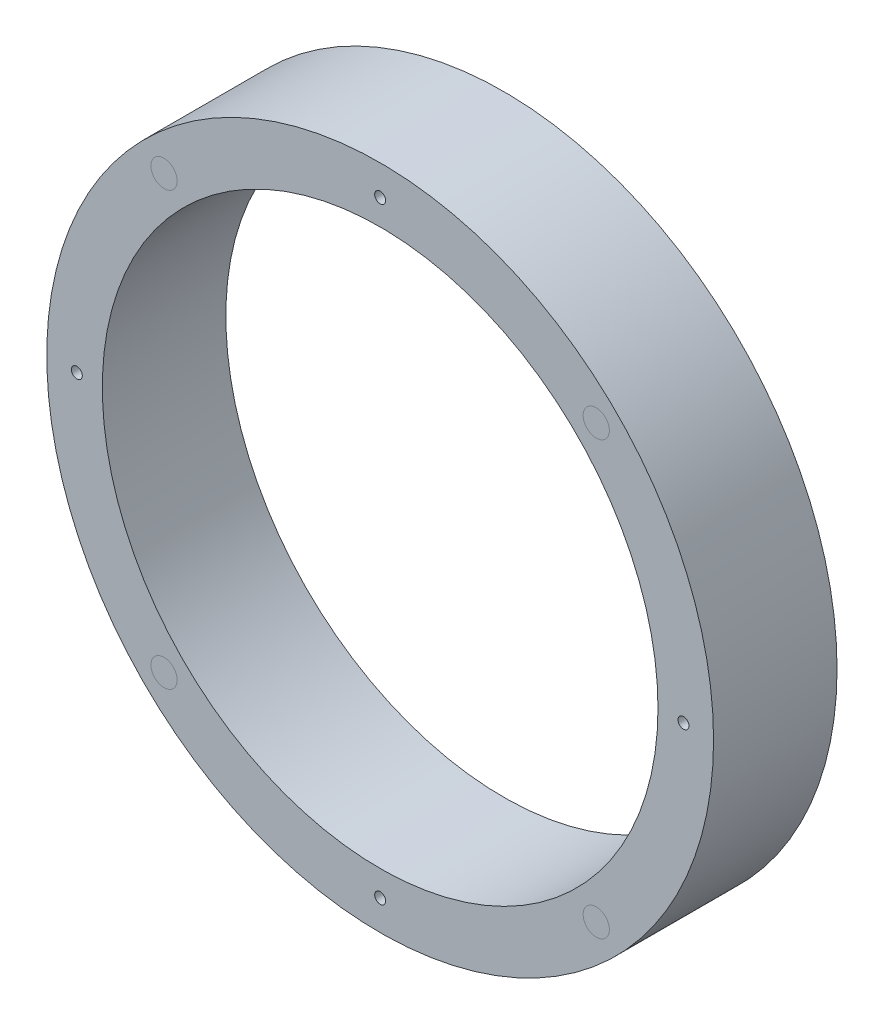
from build123d import *

# Parameters (mm, degrees)
SKETCH1_R             = 76.2
SKETCH1_R_2           = 63.5
SKETCH1_R_3           = 1.25
BOSS_EXTRUDE1_DEPTH   = 28.225
SKETCH2_R             = 2.5
CUT_EXTRUDE1_DEPTH    = 6.725
SKETCH3_R             = 3
CUT_EXTRUDE2_DEPTH    = 29.225
SKETCH4_R             = 3
BOSS_EXTRUDE2_DEPTH   = 6.45
BOSS_EXTRUDE2_2_DEPTH = 6.45
BOSS_EXTRUDE2_3_DEPTH = 6.45
BOSS_EXTRUDE2_4_DEPTH = 6.45


with BuildPart() as part:
    # Sketch1 → Boss-Extrude1 (new body)
    with BuildSketch(Plane.XY):
        Circle(SKETCH1_R)
        Circle(SKETCH1_R_2, mode=Mode.SUBTRACT)
        with Locations((0, 69.3225)):
            Circle(SKETCH1_R_3, mode=Mode.SUBTRACT)
        with Locations((69.3225, 0)):
            Circle(SKETCH1_R_3, mode=Mode.SUBTRACT)
        with Locations((0, -69.3225)):
            Circle(SKETCH1_R_3, mode=Mode.SUBTRACT)
        with Locations((-69.3225, 0)):
            Circle(SKETCH1_R_3, mode=Mode.SUBTRACT)
    extrude(amount=BOSS_EXTRUDE1_DEPTH)

    # Sketch2 → Cut-Extrude1 (cut)
    with BuildSketch(Plane(origin=(0, 0, 0), x_dir=(-1, 0, 0), z_dir=(0, 0, -1))):
        with Locations((0, 69.3225)):
            Circle(SKETCH2_R)
        with Locations((69.3225, 0)):
            Circle(SKETCH2_R)
        with Locations((0, -69.3225)):
            Circle(SKETCH2_R)
        with Locations((-69.3225, 0)):
            Circle(SKETCH2_R)
    extrude(amount=-CUT_EXTRUDE1_DEPTH, mode=Mode.SUBTRACT)

    # Sketch3 → Cut-Extrude2 (cut, through all)
    with BuildSketch(Plane.XY.offset(28.225)):
        with Locations((-49.391408666, 49.391408666)):
            Circle(SKETCH3_R)
        with Locations((49.391408666, 49.391408666)):
            Circle(SKETCH3_R)
        with Locations((49.391408666, -49.391408666)):
            Circle(SKETCH3_R)
        with Locations((-49.391408666, -49.391408666)):
            Circle(SKETCH3_R)
    extrude(amount=-CUT_EXTRUDE2_DEPTH, mode=Mode.SUBTRACT)


with BuildPart() as body_2:
    # Sketch4 → Boss-Extrude2 (new body)
    with BuildSketch(Plane.XY.offset(28.225)):
        with Locations((-49.391408666, -49.391408666)):
            Circle(SKETCH4_R)
    extrude(amount=-BOSS_EXTRUDE2_DEPTH)


with BuildPart() as body_3:
    # Sketch4 → Boss-Extrude2 2 (new body)
    with BuildSketch(Plane.XY.offset(28.225)):
        with Locations((49.391408666, -49.391408666)):
            Circle(SKETCH4_R)
    extrude(amount=-BOSS_EXTRUDE2_2_DEPTH)


with BuildPart() as body_4:
    # Sketch4 → Boss-Extrude2 3 (new body)
    with BuildSketch(Plane.XY.offset(28.225)):
        with Locations((49.391408666, 49.391408666)):
            Circle(SKETCH4_R)
    extrude(amount=-BOSS_EXTRUDE2_3_DEPTH)


with BuildPart() as body_5:
    # Sketch4 → Boss-Extrude2 4 (new body)
    with BuildSketch(Plane.XY.offset(28.225)):
        with Locations((-49.391408666, 49.391408666)):
            Circle(SKETCH4_R)
    extrude(amount=-BOSS_EXTRUDE2_4_DEPTH)


solid = Compound([part.part, body_2.part, body_3.part, body_4.part, body_5.part])
